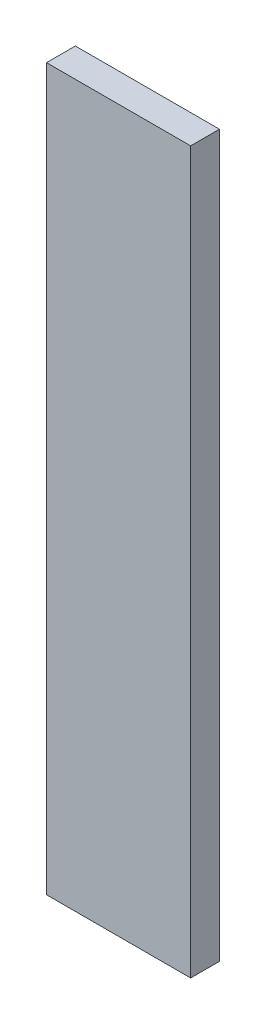
from build123d import *

# Parameters (mm, degrees)
SKETCH_1_W      = 10
SKETCH_1_H      = 2
EXTRUDE_1_DEPTH = 50


with BuildPart() as part:
    # Эскиз1 → Бобышка-Вытянуть1 (new body)
    with BuildSketch(Plane(origin=(0, 0, 0), x_dir=(1, 0, 0), z_dir=(0, 1, 0))):
        with Locations((5, 1)):
            Rectangle(SKETCH_1_W, SKETCH_1_H)
    extrude(amount=EXTRUDE_1_DEPTH)


solid = part.part
